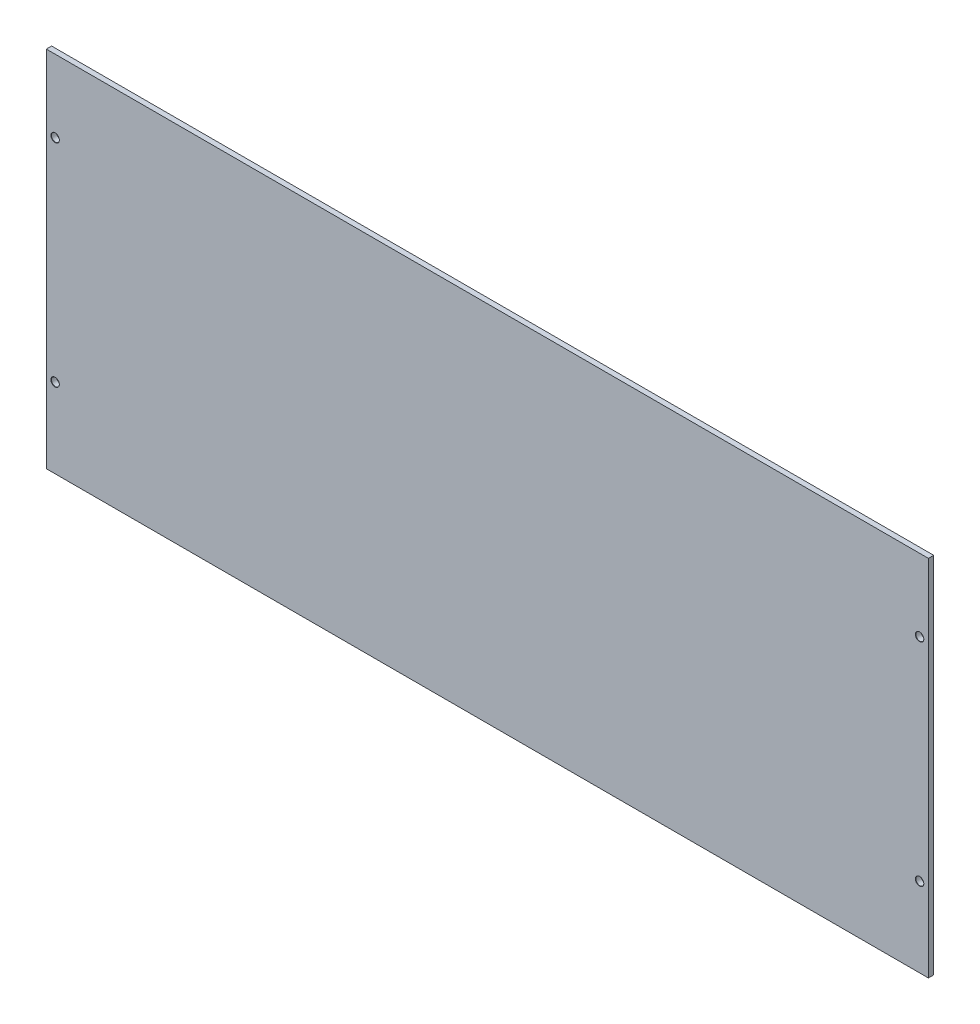
from build123d import *

# Parameters (mm, degrees)
SKETCH_1_W                  = 500
SKETCH_1_H                  = 206
EXTRUDE_1_DEPTH             = 3
HOLE_WIZARD_M41_D           = 4.5
HOLE_WIZARD_M41_DEPTH       = 10
HOLE_WIZARD_M41_CSINK_D     = 4.8
HOLE_WIZARD_M41_CSINK_ANGLE = 90
HOLE_WIZARD_M41_TIP         = 1.351936393


with BuildPart() as part:
    # Эскиз1 → Бобышка-Вытянуть1 (new body)
    with BuildSketch(Plane.XY):
        with Locations((250, 103)):
            Rectangle(SKETCH_1_W, SKETCH_1_H)
    extrude(amount=EXTRUDE_1_DEPTH)

    # Отверстие с зазором M41
    with Locations(Plane.XY.offset(3)):
        with Locations((5, 165), (5, 45), (495, 45), (495, 165)):
            CounterSinkHole(HOLE_WIZARD_M41_D / 2, HOLE_WIZARD_M41_CSINK_D / 2, depth=HOLE_WIZARD_M41_DEPTH, counter_sink_angle=HOLE_WIZARD_M41_CSINK_ANGLE)
            with Locations((0, 0, -(HOLE_WIZARD_M41_DEPTH + HOLE_WIZARD_M41_TIP / 2))):  # 118° drill point
                Cone(0, HOLE_WIZARD_M41_D / 2, HOLE_WIZARD_M41_TIP, mode=Mode.SUBTRACT)


solid = part.part
